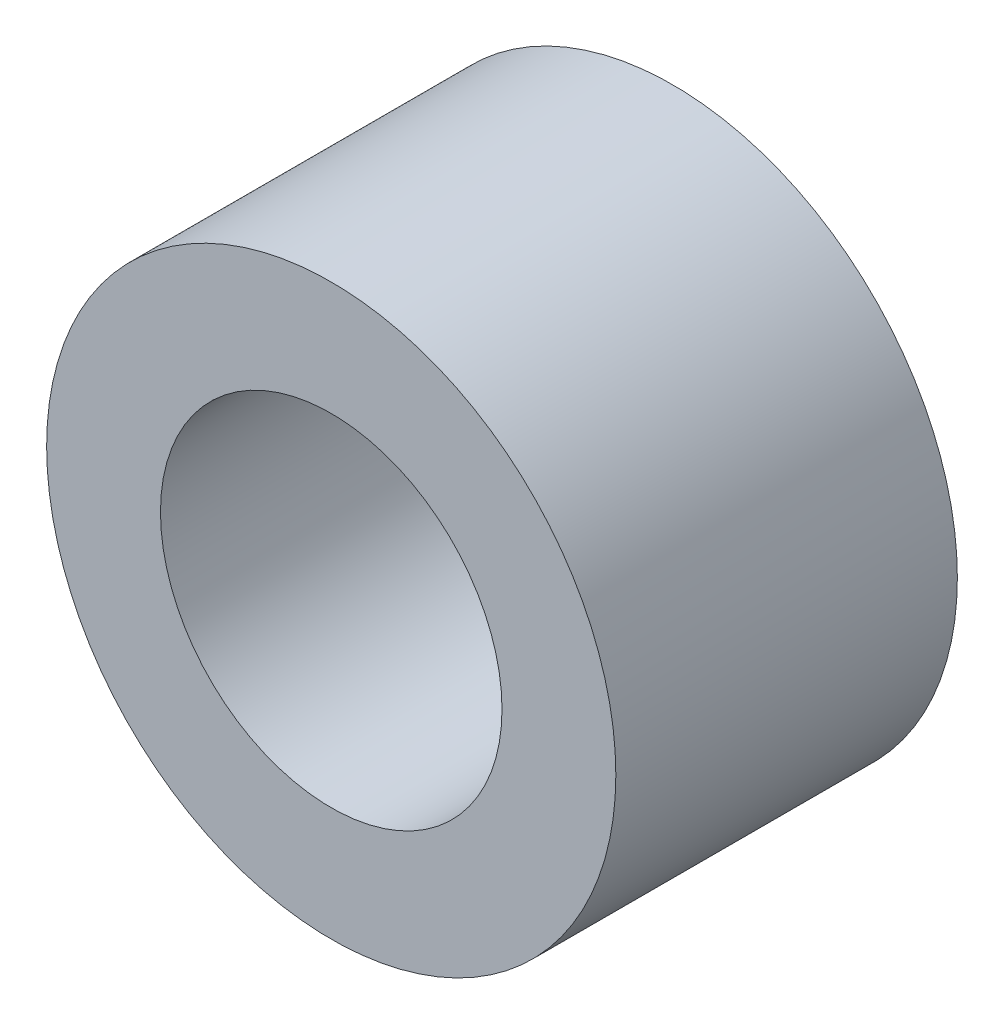
from build123d import *

# Parameters (mm, degrees)
SKETCH1_R           = 31.75
BOSS_EXTRUDE1_DEPTH = 38.1
SKETCH2_R           = 19.05
CUT_EXTRUDE1_DEPTH  = 12.7
SKETCH3_R           = 19.05
CUT_EXTRUDE2_DEPTH  = 39.1
SKETCH4_R           = 22.86
CUT_EXTRUDE3_DEPTH  = 7.62


with BuildPart() as part:
    # Sketch1 → Boss-Extrude1 (new body)
    with BuildSketch(Plane.XY):
        Circle(SKETCH1_R)
    extrude(amount=BOSS_EXTRUDE1_DEPTH)

    # Sketch2 → Cut-Extrude1 (cut)
    with BuildSketch(Plane(origin=(0, 0, 0), x_dir=(-1, 0, 0), z_dir=(0, 0, -1))):
        Circle(SKETCH2_R)
    extrude(amount=-CUT_EXTRUDE1_DEPTH, mode=Mode.SUBTRACT)

    # Sketch3 → Cut-Extrude2 (cut, through all)
    with BuildSketch(Plane.XY.offset(38.1)):
        with Locations(Location((0, 0, 0), (0, 0, 180))):  # turned: the seam where the file's is
            Circle(SKETCH3_R)
    extrude(amount=-CUT_EXTRUDE2_DEPTH, mode=Mode.SUBTRACT)

    # Sketch4 → Cut-Extrude3 (cut)
    with BuildSketch(Plane(origin=(0, 0, 0), x_dir=(-1, 0, 0), z_dir=(0, 0, -1))):
        Circle(SKETCH4_R)
    extrude(amount=-CUT_EXTRUDE3_DEPTH, mode=Mode.SUBTRACT)


solid = part.part
